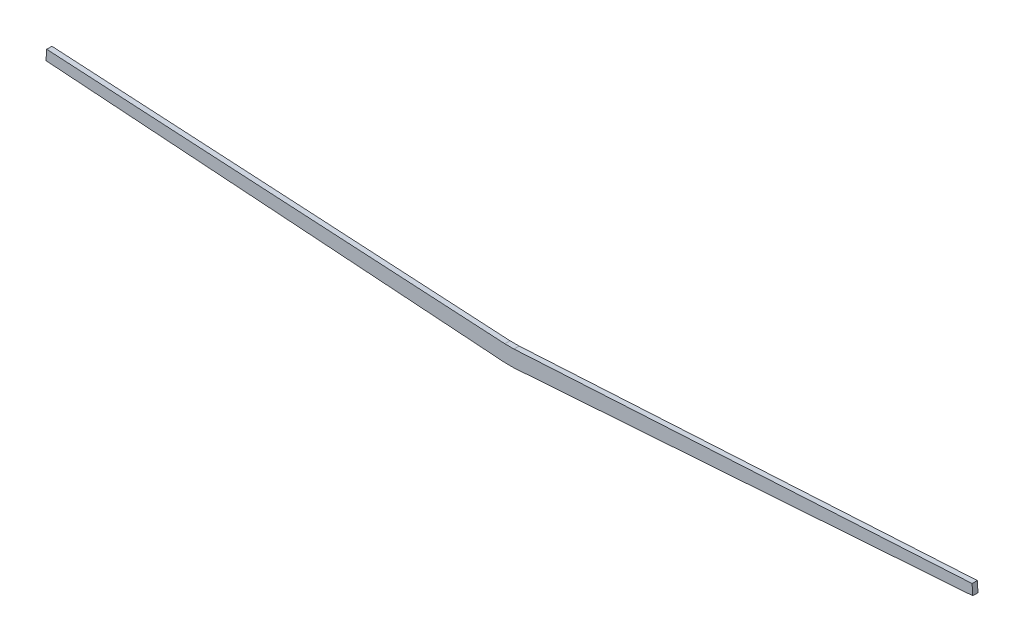
from build123d import *

# Parameters (mm, degrees)
BOSS_EXTRUDE1_DEPTH = 7.2


with BuildPart() as part:
    # Sketch1 → Boss-Extrude1 (new body)
    with BuildSketch(Plane.XY):
        Polygon((-641.321779426, 44.401552209), (-6.35, 0), (6.35, 0), (641.321779426, 44.401552209), (640.329563344, 58.59090326), (6.35, 22.606), (-6.35, 22.606), (-640.329563344, 58.59090326), align=None)
    extrude(amount=BOSS_EXTRUDE1_DEPTH)


solid = part.part
